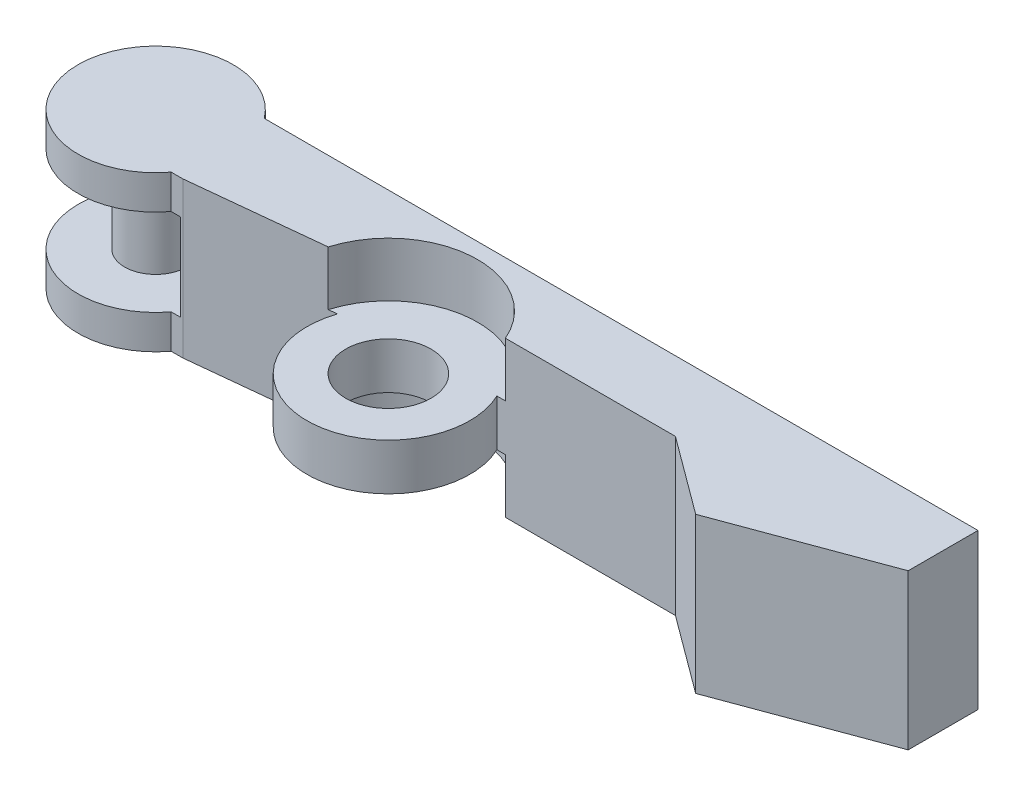
from build123d import *

# Parameters (mm, degrees)
SKETCH2_R               = 2.75
SKETCH2_R_2             = 2
BOSS_EXTRUDE1_DEPTH     = 5
CUT_EXTRUDE1_START      = 1.5
SKETCH4_R               = 5.75
CUT_EXTRUDE1_DEPTH      = 4.5
CUT_EXTRUDE2_START      = -5
SKETCH5_R               = 5.5
CUT_EXTRUDE2_DEPTH      = 2.8
CUT_EXTRUDE2_DEPTH_BACK = 2.8
SKETCH6_R               = 2
BOSS_EXTRUDE2_DEPTH     = 10


with BuildPart() as part:
    # Sketch2 → Boss-Extrude1 (new body, symmetric)
    with BuildSketch(Plane(origin=(0, 0, 0), x_dir=(1, 0, 0), z_dir=(0, 1, 0))):
        with BuildLine():
            ThreePointArc((-11.219654399, -2.057358528), (-5.949237585, -8.991377869), (-1.50658351, -1.5))
            Line((-1.50658351, -1.5), (10, -1.5))
            Line((10, -1.5), (15, -5.195678453))
            Line((15, -5.195678453), (25, -1.5))
            Line((25, -1.5), (25, 3))
            Line((25, 3), (-21, 3))
            ThreePointArc((-21, 3), (-30, 0), (-21, -3))
            Line((-21, -3), (-20.25, -3))
            Line((-20.25, -3), (-11.219654399, -2.057358528))
        make_face()
        with Locations((-6.25, -3.75)):
            Circle(SKETCH2_R, mode=Mode.SUBTRACT)
        with Locations((-25, 0)):
            Circle(SKETCH2_R_2, mode=Mode.SUBTRACT)
    extrude(amount=BOSS_EXTRUDE1_DEPTH, both=True)

    # Sketch4 → Cut-Extrude1 (cut, through all)
    with BuildSketch(Plane(origin=(0, 0, 0), x_dir=(1, 0, 0), z_dir=(0, 1, 0)).offset(CUT_EXTRUDE1_START)):
        with Locations((-6.25, -3.75)):
            Circle(SKETCH4_R)
    cut_extrude1 = extrude(amount=CUT_EXTRUDE1_DEPTH, mode=Mode.SUBTRACT)

    # Sketch5 → Cut-Extrude2 (cut, two sides)
    with BuildSketch(Plane(origin=(0, 5, 0), x_dir=(1, 0, 0), z_dir=(0, 1, 0)).offset(CUT_EXTRUDE2_START)) as cut_extrude2_sk:
        with Locations((-25, 0)):
            Circle(SKETCH5_R)
    extrude(amount=CUT_EXTRUDE2_DEPTH, mode=Mode.SUBTRACT)
    extrude(cut_extrude2_sk.sketch, amount=-CUT_EXTRUDE2_DEPTH_BACK, mode=Mode.SUBTRACT)

    # Mirror1: Cut-Extrude1 across plane
    add(cut_extrude1.mirror(Plane.ZX), mode=Mode.SUBTRACT)

    # Sketch6 → Boss-Extrude2 (add)
    with BuildSketch(Plane(origin=(0, 5, 0), x_dir=(1, 0, 0), z_dir=(0, 1, 0))):
        with Locations((-25, 0)):
            Circle(SKETCH6_R)
    extrude(amount=-BOSS_EXTRUDE2_DEPTH)


solid = part.part
